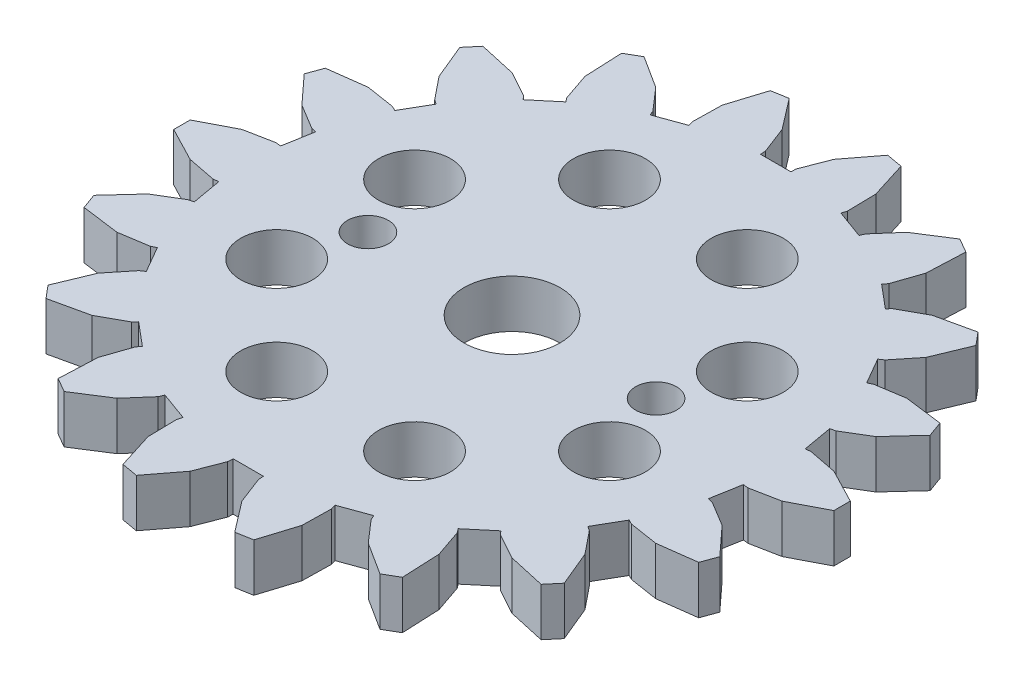
from build123d import *

# Parameters (mm, degrees)
BOSS_EXTRUDE1_DEPTH = 4
CUT_EXTRUDE1_REACH  = 6
SKETCH3_R           = 4
SKETCH3_R_2         = 1.7
SKETCH4_R           = 3
CUT_EXTRUDE2_DEPTH  = 4
CIRPATTERN1_COUNT   = 8


with BuildPart() as part:
    # Sketch2 → Boss-Extrude1 (new body)
    with BuildSketch(Plane(origin=(0, 0, 0), x_dir=(1, 0, 0), z_dir=(0, 1, 0))):
        Polygon((52.538734218, 31.842538875), (52.966809318, 31.892862657), (55.345625477, 31.426126758), (58.18102676, 29.953783051), (58.18102676, 28.584463126), (55.345625477, 27.112119419), (52.966809318, 26.64538352), (52.538734218, 26.695707302), (52.101156541, 24.214732135), (52.520808121, 24.115596779), (54.59638672, 22.863553353), (56.757494627, 20.510006991), (56.289031474, 19.223191192), (53.12080355, 18.809586915), (50.72600436, 19.184530393), (50.340910107, 19.378265245), (49.081307935, 17.196423401), (49.441564779, 16.959924277), (50.963799881, 15.07332886), (52.189708735, 12.122809954), (51.309369324, 11.073573865), (48.190601939, 11.768601179), (46.068586453, 12.939866968), (45.772908404, 13.25368769), (43.842900517, 11.634261062), (44.100782542, 11.288690853), (44.885873492, 8.995402472), (45.028637129, 5.803632771), (43.842684706, 5.118756998), (41.149615437, 6.838398802), (39.556106805, 8.664951285), (39.385697153, 9.061061087), (37.018327401, 8.199295971), (37.142300931, 7.786339893), (37.095648999, 5.362815632), (36.138204566, 2.314673579), (34.789402002, 2.076878058), (32.847083699, 4.613576876), (31.97451961, 6.875115771), (31.949681435, 7.305566323), (29.430477092, 7.305566323), (29.405639683, 6.875115771), (28.533075594, 4.613576876), (26.590757291, 2.076878058), (25.241954726, 2.314673579), (24.284510294, 5.362815632), (24.237858361, 7.786339893), (24.361831127, 8.199295971), (21.994461374, 9.061061087), (21.824052488, 8.664951285), (20.230543856, 6.838398802), (17.537474587, 5.118756998), (16.351521398, 5.803632771), (16.494285035, 8.995402472), (17.279376751, 11.288690853), (17.537258011, 11.634261062), (15.607250889, 13.25368769), (15.311572074, 12.939866968), (13.189557354, 11.768601179), (10.070789203, 11.073573865), (9.190449792, 12.122809954), (10.416359412, 15.07332886), (11.938594514, 16.959924277), (12.298851357, 17.196423401), (11.039249186, 19.378265245), (10.654154168, 19.184530393), (8.259354977, 18.809586915), (5.091127819, 19.223191192), (4.622664666, 20.510006991), (6.783771808, 22.863553353), (8.859351172, 24.115596779), (9.279002752, 24.214732135), (8.84142431, 26.695707302), (8.413349975, 26.64538352), (6.034533051, 27.112119419), (3.199132533, 28.584463126), (3.199132533, 29.953783051), (6.034533051, 31.426126758), (8.413349975, 31.892862657), (8.84142431, 31.842538875), (9.279002752, 34.323514042), (8.859351172, 34.422649398), (6.783771808, 35.674692824), (4.622664666, 38.028239186), (5.091127819, 39.315054985), (8.259354977, 39.728659262), (10.654154168, 39.353715784), (11.039249186, 39.159980932), (12.298851357, 41.341822776), (11.938594514, 41.5783219), (10.416359412, 43.464917317), (9.190449792, 46.415436223), (10.070789203, 47.464672312), (13.189557354, 46.769644998), (15.311572074, 45.598379209), (15.607250889, 45.284558487), (17.537258011, 46.903985115), (17.279376751, 47.249555324), (16.494285035, 49.542843705), (16.351521398, 52.734613406), (17.537474587, 53.41948918), (20.230543856, 51.699847375), (21.824052488, 49.873294892), (21.994461374, 49.47718509), (24.361831127, 50.338950206), (24.237858361, 50.751906284), (24.284510294, 53.175430545), (25.241954726, 56.223572598), (26.590757291, 56.46136812), (28.533075594, 53.924669301), (29.405639683, 51.663130406), (29.430477092, 51.232679854), (31.949681435, 51.232679854), (31.97451961, 51.663130406), (32.847083699, 53.924669301), (34.789402002, 56.46136812), (36.138204566, 56.223572598), (37.095648999, 53.175430545), (37.142300931, 50.751906284), (37.018327401, 50.338950206), (39.385697153, 49.47718509), (39.556106805, 49.873294892), (41.149615437, 51.699847375), (43.842684706, 53.41948918), (45.028637129, 52.734613406), (44.885873492, 49.542843705), (44.100782542, 47.249555324), (43.842900517, 46.903985115), (45.772908404, 45.284558487), (46.068586453, 45.598379209), (48.190601939, 46.769644998), (51.309369324, 47.464672312), (52.189708735, 46.415436223), (50.963799881, 43.464917317), (49.441564779, 41.5783219), (49.081307935, 41.341822776), (50.340910107, 39.159980932), (50.72600436, 39.353715784), (53.12080355, 39.728659262), (56.289031474, 39.315054985), (56.757494627, 38.028239186), (54.59638672, 35.674692824), (52.520808121, 34.422649398), (52.101156541, 34.323514042), align=None)
    extrude(amount=BOSS_EXTRUDE1_DEPTH)

    # Sketch3 → Cut-Extrude1 (cut, up to next)
    with BuildSketch(Plane(origin=(0, 0, 0), x_dir=(1, 0, 0), z_dir=(0, 1, 0)), mode=Mode.PRIVATE) as cut_extrude1_sk1:
        with Locations((30.690079264, 29.269123089)):
            Circle(SKETCH3_R)
    cut_extrude1_tool1 = extrude(cut_extrude1_sk1.sketch, amount=CUT_EXTRUDE1_REACH, mode=Mode.PRIVATE) & part.part
    add(cut_extrude1_tool1.solids().sort_by_distance((30.690079, 0, -29.269123))[0], mode=Mode.SUBTRACT)
    # Sketch3 → Cut-Extrude1 (cut, up to next)
    with BuildSketch(Plane(origin=(0, 0, 0), x_dir=(1, 0, 0), z_dir=(0, 1, 0)), mode=Mode.PRIVATE) as cut_extrude1_sk2:
        with Locations((18.690079264, 29.269123089)):
            Circle(SKETCH3_R_2)
    cut_extrude1_tool2 = extrude(cut_extrude1_sk2.sketch, amount=CUT_EXTRUDE1_REACH, mode=Mode.PRIVATE) & part.part
    add(cut_extrude1_tool2.solids().sort_by_distance((18.690079, 0, -29.269123))[0], mode=Mode.SUBTRACT)
    # Sketch3 → Cut-Extrude1 (cut, up to next)
    with BuildSketch(Plane(origin=(0, 0, 0), x_dir=(1, 0, 0), z_dir=(0, 1, 0)), mode=Mode.PRIVATE) as cut_extrude1_sk3:
        with Locations((42.690079264, 29.269123089)):
            Circle(SKETCH3_R_2)
    cut_extrude1_tool3 = extrude(cut_extrude1_sk3.sketch, amount=CUT_EXTRUDE1_REACH, mode=Mode.PRIVATE) & part.part
    add(cut_extrude1_tool3.solids().sort_by_distance((42.690079, 0, -29.269123))[0], mode=Mode.SUBTRACT)

    # Sketch4 → Cut-Extrude2 (cut)
    with BuildSketch(Plane(origin=(0, 0, 0), x_dir=(1, 0, 0), z_dir=(0, 1, 0))):
        with Locations((16.831886276, 35.009374574)):
            Circle(SKETCH4_R)
    cut_extrude2 = extrude(amount=CUT_EXTRUDE2_DEPTH, mode=Mode.SUBTRACT)

    # CirPattern1: Cut-Extrude2 ×8 about axis
    cirpattern1_axis = Axis((30.690079264, 0, -29.269123089), (0, 1, 0))
    for i in range(1, CIRPATTERN1_COUNT):
        add(cut_extrude2.rotate(cirpattern1_axis, i * 360 / CIRPATTERN1_COUNT), mode=Mode.SUBTRACT)


solid = part.part
